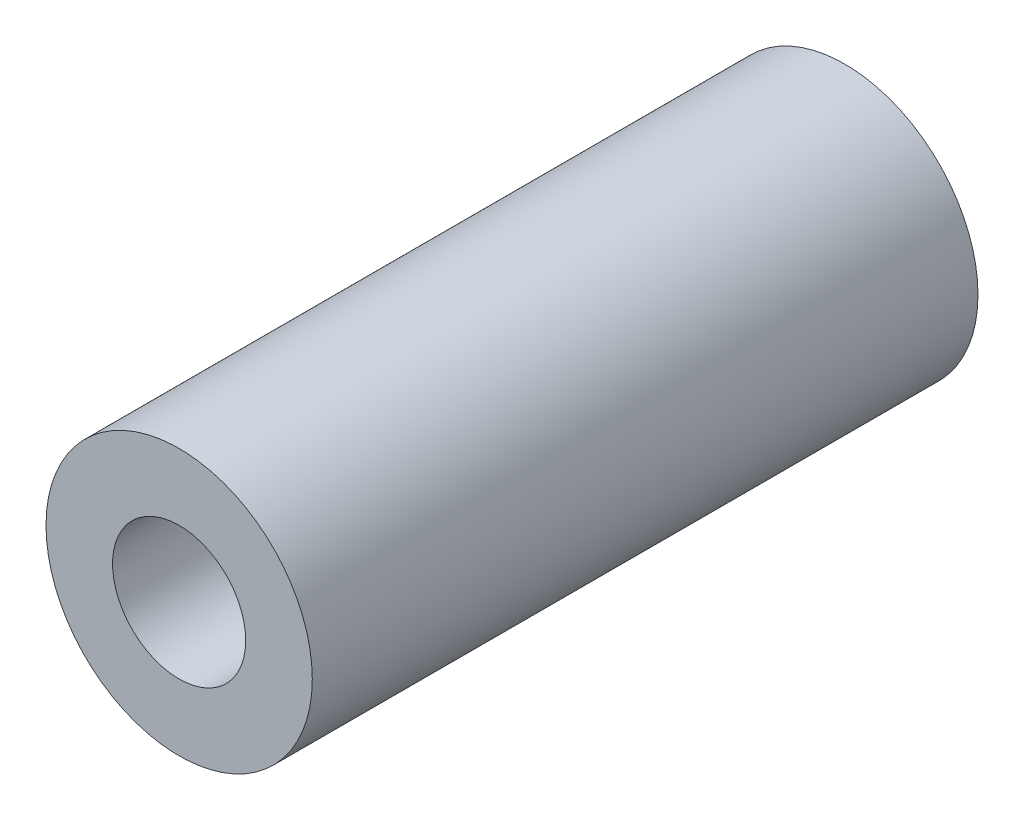
from build123d import *

# Parameters (mm, degrees)
SKETCH_1_R      = 3
SKETCH_1_R_2    = 1.5
EXTRUDE_1_DEPTH = 7.5


with BuildPart() as part:
    # 草图1 → 凸台-拉伸1 (new body, symmetric)
    with BuildSketch(Plane.XY):
        Circle(SKETCH_1_R)
        Circle(SKETCH_1_R_2, mode=Mode.SUBTRACT)
    extrude(amount=EXTRUDE_1_DEPTH, both=True)


solid = part.part
